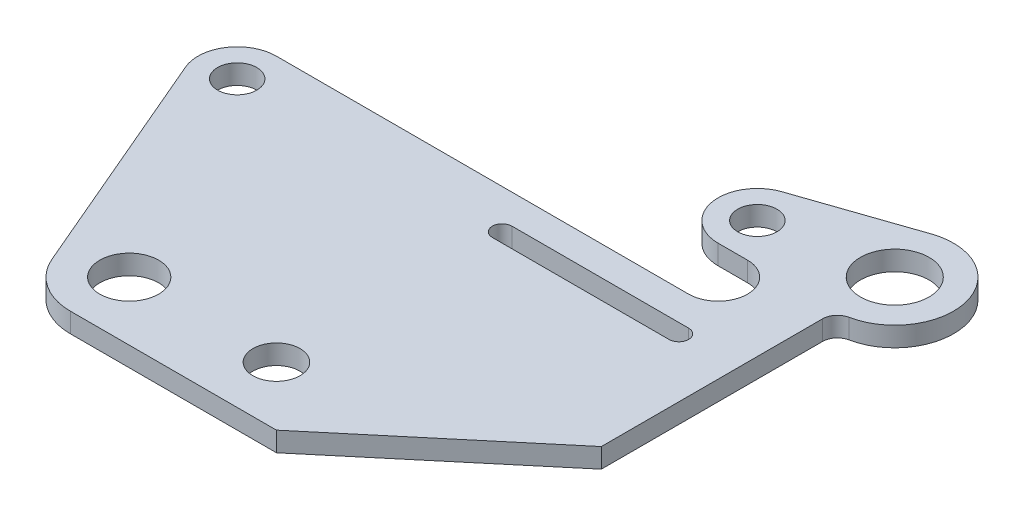
from build123d import *

# Parameters (mm, degrees)
SKETCH1_R           = 25.4
SKETCH1_R_2         = 38.1
SKETCH1_R_3         = 44.45
SKETCH1_R_4         = 30.48
BOSS_EXTRUDE1_DEPTH = 12.7


with BuildPart() as part:
    # Sketch1 → Boss-Extrude1 (new body, symmetric)
    with BuildSketch(Plane(origin=(0, 0, 0), x_dir=(1, 0, 0), z_dir=(0, 1, 0))):
        with BuildLine():
            Line((-199.116056599, 272.143796557), (-70.074084898, -29.934305164))
            ThreePointArc((-70.074084898, -29.934305164), (-41.984794548, -63.590227447), (0, -76.2))
            Line((0, -76.2), (266.7, -76.2))
            Line((266.7, -76.2), (495.3, 115.618175687))
            Line((495.3, 115.618175687), (495.3, 401.9744408))
            ThreePointArc((495.3, 401.9744408), (499.593933451, 414.022718685), (510.54, 420.63955264))
            ThreePointArc((510.54, 420.63955264), (568.823505812, 515.318343915), (470.586486486, 567.381081081))
            Line((470.586486486, 567.381081081), (326.424324324, 517.954054054))
            ThreePointArc((326.424324324, 517.954054054), (292.791188669, 461.548531445), (342.9, 419.1))
            Line((342.9, 419.1), (381, 419.1))
            ThreePointArc((381, 419.1), (419.1, 381), (381, 342.9))
            Line((381, 342.9), (-152.4, 342.9))
            ThreePointArc((-152.4, 342.9), (-194.793484965, 320.089863032), (-199.116056599, 272.143796557))
        make_face()
        with Locations((-152.4, 292.1)):
            Circle(SKETCH1_R, mode=Mode.SUBTRACT)
        Circle(SKETCH1_R_2, mode=Mode.SUBTRACT)
        with Locations((342.9, 469.9)):
            Circle(SKETCH1_R, mode=Mode.SUBTRACT)
        with Locations((495.3, 495.3)):
            Circle(SKETCH1_R_3, mode=Mode.SUBTRACT)
        with Locations((190.5, 0)):
            Circle(SKETCH1_R_4, mode=Mode.SUBTRACT)
        with BuildLine():
            Line((190.5, 304.8), (419.1, 304.8))
            ThreePointArc((419.1, 304.8), (431.8, 292.1), (419.1, 279.4))
            Line((419.1, 279.4), (190.5, 279.4))
            ThreePointArc((190.5, 279.4), (177.8, 292.1), (190.5, 304.8))
        make_face(mode=Mode.SUBTRACT)
    extrude(amount=BOSS_EXTRUDE1_DEPTH, both=True)


solid = part.part
